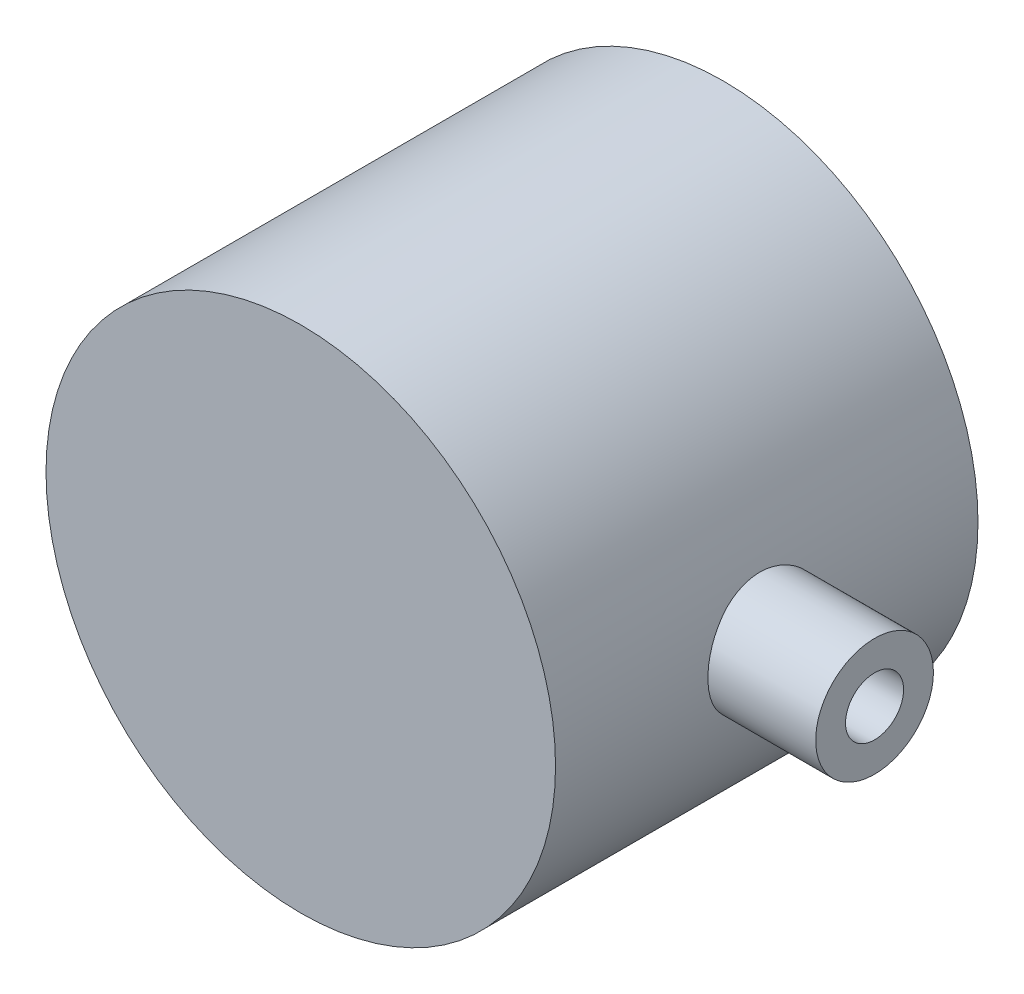
from build123d import *

# Parameters (mm, degrees)
SKETCH1_R                = 24.123
BOSS_EXTRUDE1_DEPTH      = 35
BOSS_EXTRUDE1_DEPTH_BACK = 5
SKETCH2_R                = 3.25
CUT_EXTRUDE2_DEPTH       = 19.25
SKETCH4_R                = 2.75
CUT_EXTRUDE3_DEPTH       = 200
CUT_EXTRUDE9_START       = -24.123
SKETCH6_R                = 5.25
CUT_EXTRUDE9_DEPTH       = 4.533
SKETCH7_R                = 17.25
CUT_EXTRUDE10_DEPTH      = 30
CUT_EXTRUDE11_START      = 19.25
SKETCH8_R                = 2.75
CUT_EXTRUDE11_DEPTH      = 24.873
BOSS_EXTRUDE2_START      = 23.125
SKETCH9_R                = 5.575
BOSS_EXTRUDE2_DEPTH      = 11.203
CUT_EXTRUDE12_DEPTH      = 50
CUT_EXTRUDE14_START      = -24.125
SKETCH12_R               = 8.25
CUT_EXTRUDE14_DEPTH      = 2
SKETCH13_R               = 3.25
CUT_EXTRUDE15_DEPTH      = 19.09
CIRPATTERN1_COUNT        = 2
CIRPATTERN1_ANGLE        = 45


with BuildPart() as part:
    # Sketch1 → Boss-Extrude1 (new body, two sides)
    with BuildSketch(Plane.XY) as boss_extrude1_sk:
        Circle(SKETCH1_R)
    extrude(amount=BOSS_EXTRUDE1_DEPTH)
    extrude(boss_extrude1_sk.sketch, amount=-BOSS_EXTRUDE1_DEPTH_BACK)

    # Sketch2 → Cut-Extrude2 (cut)
    with BuildSketch(Plane(origin=(0, 0, 0), x_dir=(0, 0, -1), z_dir=(1, 0, 0))):
        with Locations((-15, 0)):
            Circle(SKETCH2_R)
    extrude(amount=CUT_EXTRUDE2_DEPTH, mode=Mode.SUBTRACT)

    # Sketch4 → Cut-Extrude3 (cut)
    with BuildSketch(Plane(origin=(0, 0, 0), x_dir=(1, 0, 0), z_dir=(0, 1, 0))):
        with Locations((0, -15)):
            Circle(SKETCH4_R)
    cut_extrude3 = extrude(amount=-CUT_EXTRUDE3_DEPTH, mode=Mode.SUBTRACT)

    # Sketch6 → Cut-Extrude9 (cut)
    with BuildSketch(Plane(origin=(0, 0, 0), x_dir=(1, 0, 0), z_dir=(0, 1, 0)).offset(CUT_EXTRUDE9_START)):
        with Locations((0, -15)):
            Circle(SKETCH6_R)
    cut_extrude9 = extrude(amount=CUT_EXTRUDE9_DEPTH, mode=Mode.SUBTRACT)

    # Sketch7 → Cut-Extrude10 (cut)
    with BuildSketch(Plane(origin=(0, 0, -5), x_dir=(-1, 0, 0), z_dir=(0, 0, -1))):
        Circle(SKETCH7_R)
    extrude(amount=-CUT_EXTRUDE10_DEPTH, mode=Mode.SUBTRACT)

    # Sketch8 → Cut-Extrude11 (cut)
    with BuildSketch(Plane(origin=(0, 0, 0), x_dir=(0, 0, -1), z_dir=(1, 0, 0)).offset(CUT_EXTRUDE11_START)):
        with Locations((-15, 0)):
            Circle(SKETCH8_R)
    extrude(amount=CUT_EXTRUDE11_DEPTH, mode=Mode.SUBTRACT)

    # Sketch12 → Cut-Extrude14 (cut)
    with BuildSketch(Plane(origin=(0, 0, 0), x_dir=(1, 0, 0), z_dir=(0, 1, 0)).offset(CUT_EXTRUDE14_START)):
        with Locations((0, -15)):
            Circle(SKETCH12_R)
    cut_extrude14 = extrude(amount=CUT_EXTRUDE14_DEPTH, mode=Mode.SUBTRACT)

    # Sketch13 → Cut-Extrude15 (cut)
    with BuildSketch(Plane(origin=(0, 0, 0), x_dir=(1, 0, 0), z_dir=(0, 1, 0))):
        with Locations((0, -15)):
            Circle(SKETCH13_R)
    cut_extrude15 = extrude(amount=-CUT_EXTRUDE15_DEPTH, mode=Mode.SUBTRACT)

    # CirPattern1: Cut-Extrude3, Cut-Extrude9, Cut-Extrude14, Cut-Extrude15 ×2 about axis
    cirpattern1_axis = Axis((0, 0, 25), (0, 0, -1))
    for i in range(1, CIRPATTERN1_COUNT):
        add(cut_extrude3.rotate(cirpattern1_axis, i * CIRPATTERN1_ANGLE / (CIRPATTERN1_COUNT - 1)), mode=Mode.SUBTRACT)
        add(cut_extrude9.rotate(cirpattern1_axis, i * CIRPATTERN1_ANGLE / (CIRPATTERN1_COUNT - 1)), mode=Mode.SUBTRACT)
        add(cut_extrude14.rotate(cirpattern1_axis, i * CIRPATTERN1_ANGLE / (CIRPATTERN1_COUNT - 1)), mode=Mode.SUBTRACT)
        add(cut_extrude15.rotate(cirpattern1_axis, i * CIRPATTERN1_ANGLE / (CIRPATTERN1_COUNT - 1)), mode=Mode.SUBTRACT)


with BuildPart() as body_2:
    # Sketch9 → Boss-Extrude2 (new body)
    with BuildSketch(Plane(origin=(0, 0, 0), x_dir=(0, 0, -1), z_dir=(1, 0, 0)).offset(BOSS_EXTRUDE2_START)):
        with Locations((-15, 0)):
            Circle(SKETCH9_R)
    extrude(amount=BOSS_EXTRUDE2_DEPTH)

    # Sketch8 → Cut-Extrude12 (cut)
    with BuildSketch(Plane(origin=(0, 0, 0), x_dir=(0, 0, -1), z_dir=(1, 0, 0))):
        with Locations((-15, 0)):
            Circle(SKETCH8_R)
    extrude(amount=CUT_EXTRUDE12_DEPTH, mode=Mode.SUBTRACT)


solid = Compound([part.part, body_2.part])
